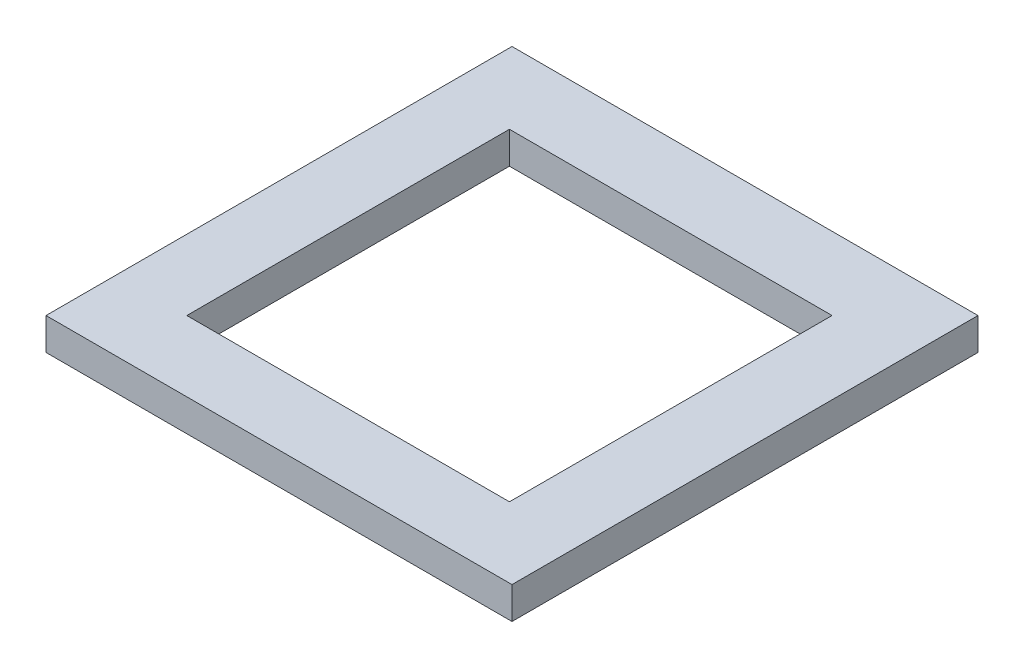
from build123d import *

# Parameters (mm, degrees)
SKETCH1_W           = 46.228
SKETCH1_H           = 46.228
SKETCH1_W_2         = 32.004
SKETCH1_H_2         = 32.004
BOSS_EXTRUDE1_DEPTH = 3.175


with BuildPart() as part:
    # Sketch1 → Boss-Extrude1 (new body)
    with BuildSketch(Plane(origin=(0, 0, 0), x_dir=(1, 0, 0), z_dir=(0, 1, 0))):
        with Locations((273.361530674, 308.401805935)):
            Rectangle(SKETCH1_W, SKETCH1_H)
        with Locations((273.234530674, 308.274805935)):
            Rectangle(SKETCH1_W_2, SKETCH1_H_2, mode=Mode.SUBTRACT)
    extrude(amount=BOSS_EXTRUDE1_DEPTH)


solid = part.part
